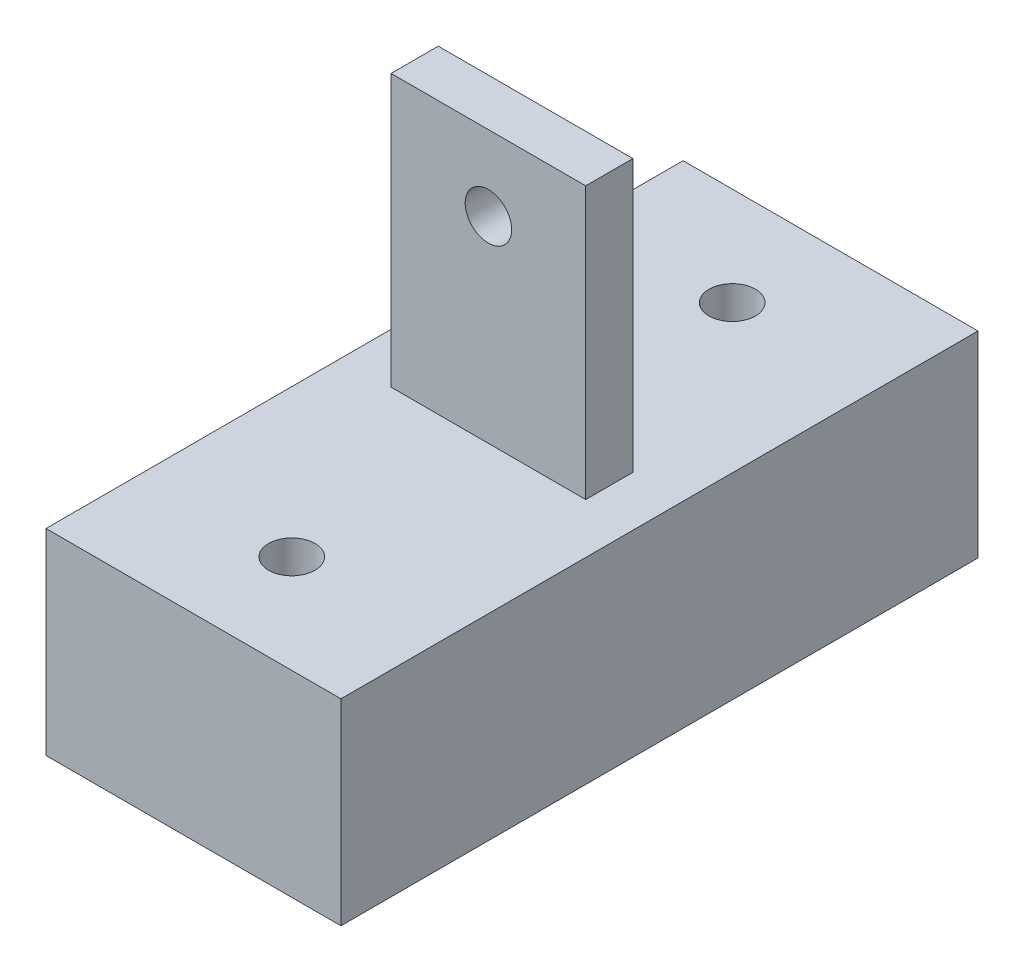
from build123d import *

# Parameters (mm, degrees)
BOSS_EXTRUDE1_DEPTH = 9.525
SKETCH1_3_W         = 3.048
SKETCH1_3_H         = 25.4
BOSS_EXTRUDE2_DEPTH = 6.2865
SKETCH2_R           = 1.5
CUT_EXTRUDE1_DEPTH  = 46.06281426
SKETCH3_W           = 12.573
SKETCH3_H           = 7.85
CUT_EXTRUDE2_DEPTH  = 46.06281426
SKETCH4_R           = 1.5
CUT_EXTRUDE3_DEPTH  = 29.670849325
SKETCH5_R           = 4.7625
CUT_EXTRUDE4_DEPTH  = 6.35


with BuildPart() as part:
    # Sketch1 → Boss-Extrude1 (new, symmetric)
    with BuildSketch(Plane(origin=(0, 0, 0), x_dir=(0, 0, -1), z_dir=(1, 0, 0))):
        Polygon((-1.524, 12.7), (-20.574, 12.7), (-20.574, 0), (20.574, 0), (20.574, 12.7), (1.524, 12.7), align=None)
    extrude(amount=BOSS_EXTRUDE1_DEPTH, both=True)

    # Sketch1_3 → Boss-Extrude2 (add, symmetric)
    with BuildSketch(Plane(origin=(0, 0, 0), x_dir=(0, 0, -1), z_dir=(1, 0, 0))):
        with Locations((0, 25.4)):
            Rectangle(SKETCH1_3_W, SKETCH1_3_H)
    extrude(amount=BOSS_EXTRUDE2_DEPTH, both=True)

    # Sketch2 → Cut-Extrude1 (cut, through all)
    with BuildSketch(Plane.XY.offset(1.524)):
        with Locations((0, 25.4)):
            Circle(SKETCH2_R)
        with Locations((0, 31.75)):
            Circle(SKETCH2_R)
    extrude(amount=-CUT_EXTRUDE1_DEPTH, mode=Mode.SUBTRACT)

    # Sketch3 → Cut-Extrude2 (cut, through all)
    with BuildSketch(Plane.XY.offset(1.524)):
        with Locations((0, 34.175)):
            Rectangle(SKETCH3_W, SKETCH3_H)
    extrude(amount=-CUT_EXTRUDE2_DEPTH, mode=Mode.SUBTRACT)

    # Sketch4 → Cut-Extrude3 (cut, through all)
    with BuildSketch(Plane(origin=(0, 12.7, 0), x_dir=(1, 0, 0), z_dir=(0, 1, 0))):
        with Locations((0, -14.224)):
            Circle(SKETCH4_R)
        with Locations((0, 14.224)):
            Circle(SKETCH4_R)
    extrude(amount=-CUT_EXTRUDE3_DEPTH, mode=Mode.SUBTRACT)

    # Sketch5 → Cut-Extrude4 (cut)
    with BuildSketch(Plane.XZ):
        with Locations((0, 14.224)):
            Circle(SKETCH5_R)
        with Locations((0, -14.224)):
            Circle(SKETCH5_R)
    extrude(amount=-CUT_EXTRUDE4_DEPTH, mode=Mode.SUBTRACT)


solid = part.part
